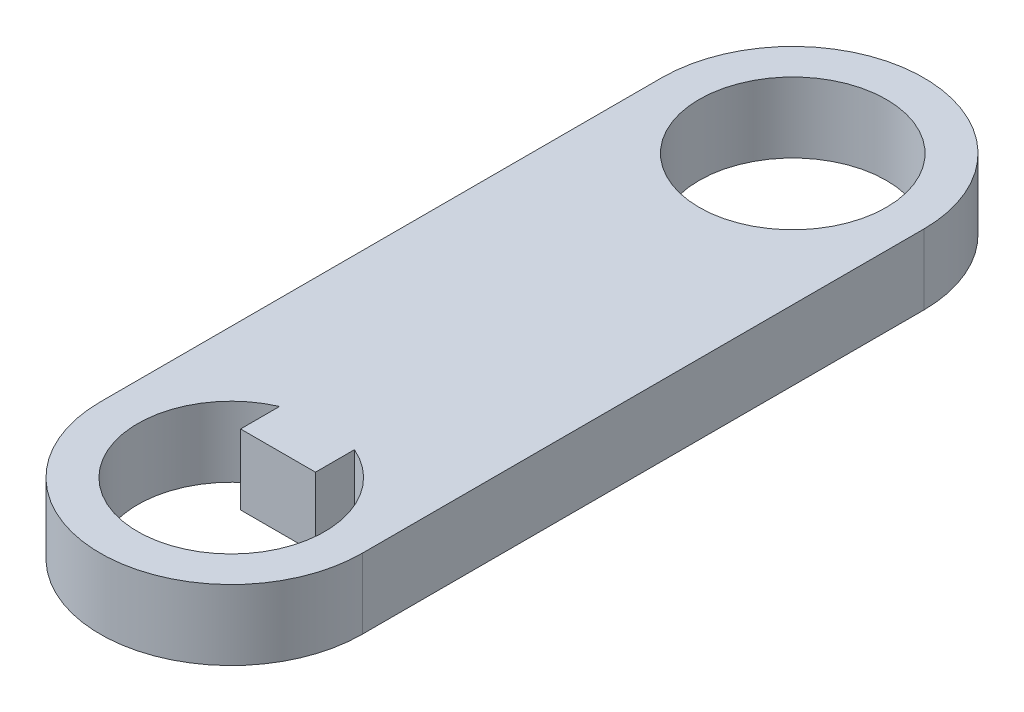
from build123d import *

# Parameters (mm, degrees)
SKETCH1_R           = 10
BOSS_EXTRUDE1_DEPTH = 7.5


with BuildPart() as part:
    # Sketch1 → Boss-Extrude1 (new body)
    with BuildSketch(Plane(origin=(0, 0, 0), x_dir=(1, 0, 0), z_dir=(0, 1, 0))):
        with BuildLine():
            Line((14, 0), (14, 60))
            ThreePointArc((14, 60), (0, 74), (-14, 60))
            Line((-14, 60), (-14, 0))
            ThreePointArc((-14, 0), (0, -14), (14, 0))
        make_face()
        with BuildLine():
            ThreePointArc((4, 9.16515139), (0, -10), (-4, 9.16515139))
            Line((-4, 9.16515139), (-4, 5))
            Line((-4, 5), (4, 5))
            Line((4, 5), (4, 9.16515139))
        make_face(mode=Mode.SUBTRACT)
        with Locations((0, 60)):
            Circle(SKETCH1_R, mode=Mode.SUBTRACT)
    extrude(amount=BOSS_EXTRUDE1_DEPTH)


solid = part.part
